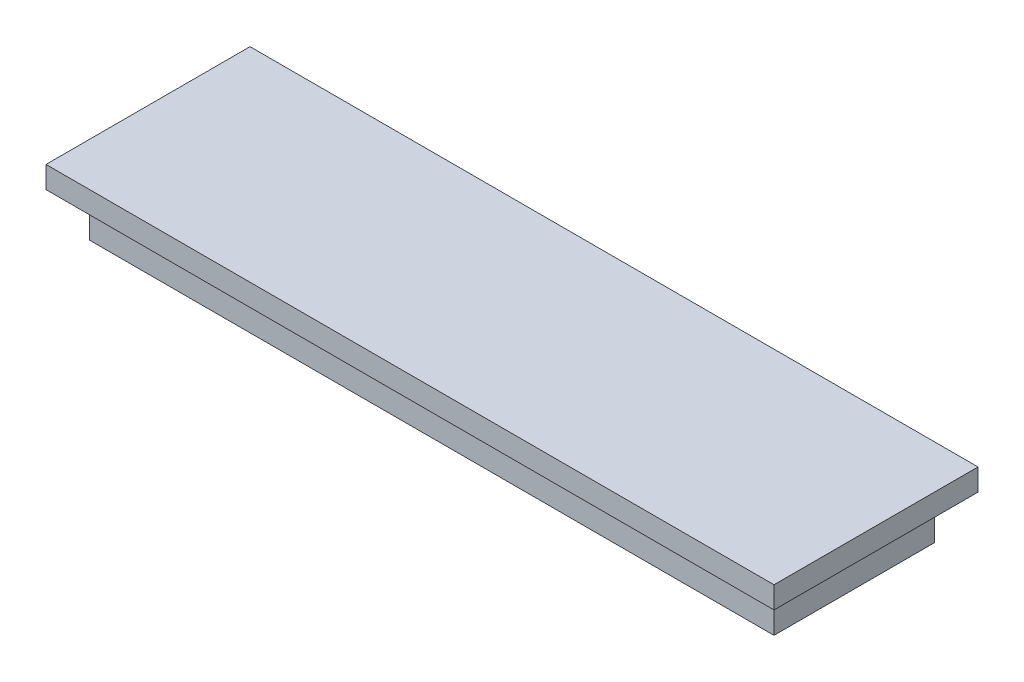
from build123d import *

# Parameters (mm, degrees)
SKETCH1_W           = 49.784
SKETCH1_H           = 11.684
BOSS_EXTRUDE1_DEPTH = 3.175
SKETCH2_W           = 52.9336
SKETCH2_H           = 14.8336
BOSS_EXTRUDE2_DEPTH = 1.5875


with BuildPart() as part:
    # Sketch1 → Boss-Extrude1 (new body)
    with BuildSketch(Plane(origin=(0, 0, 0), x_dir=(1, 0, 0), z_dir=(0, 1, 0))):
        Rectangle(SKETCH1_W, SKETCH1_H)
    extrude(amount=BOSS_EXTRUDE1_DEPTH)

    # Sketch2 → Boss-Extrude2 (add)
    with BuildSketch(Plane(origin=(0, 3.175, 0), x_dir=(1, 0, 0), z_dir=(0, 1, 0))):
        Rectangle(SKETCH2_W, SKETCH2_H)
    extrude(amount=BOSS_EXTRUDE2_DEPTH)


solid = part.part
